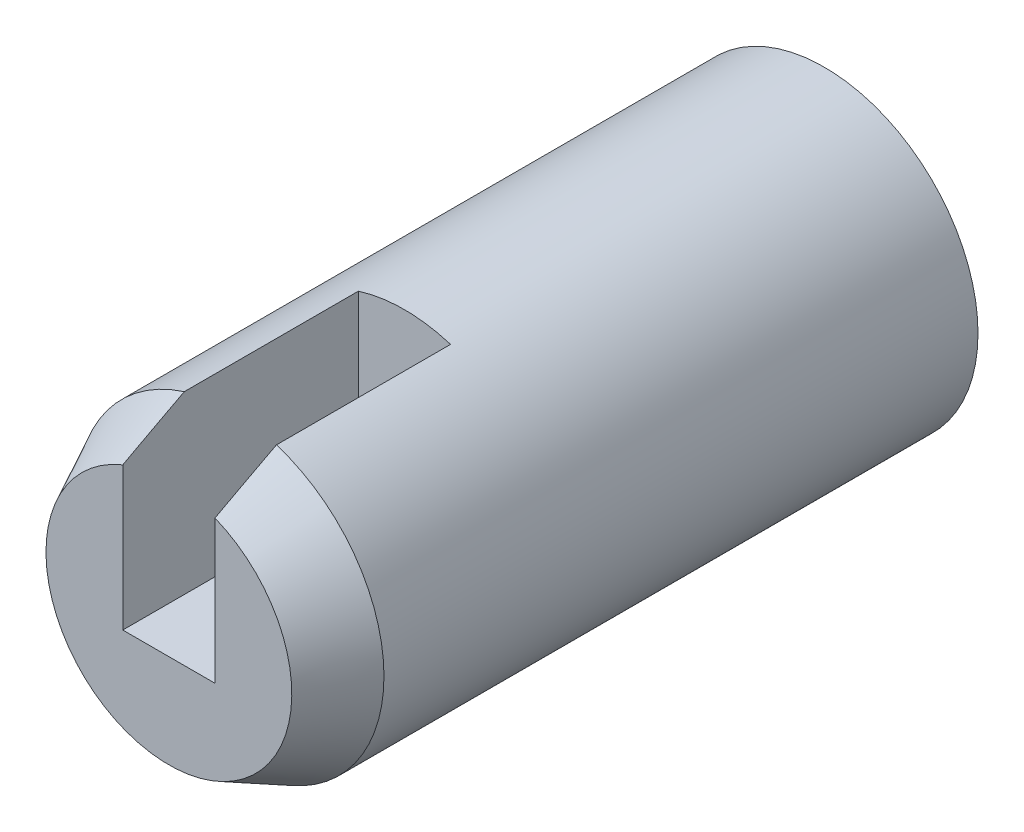
from build123d import *

# Parameters (mm, degrees)
ESQUISSE1_R             = 7.5
BOSS_EXTRU_2_DEPTH      = 29
ESQUISSE10_R            = 6
ESQUISSE11_R            = 6
ENL_V_MAT_EXTRU_1_DEPTH = 8
ENL_V_MAT_EXTRU_2_DEPTH = 11.5


with BuildPart() as part:
    # Esquisse1 → Boss.-Extru.2 (new body)
    with BuildSketch(Plane.XY):
        with Locations(Location((-15.770569557, 6.529797245, 0), (0, 0, 180))):
            Circle(ESQUISSE1_R)
    extrude(amount=BOSS_EXTRU_2_DEPTH)

    # Esquisse10 → section 1 of lissage3
    with BuildSketch(Plane.XY.offset(32), mode=Mode.PRIVATE) as lissage3_s1:
        with Locations((-15.770569557, 6.529797245)):
            Circle(ESQUISSE10_R)
    # loft up to a face of the part (lissage3)
    loft([Face(Wire([part.edges().sort_by_distance((-10.636466262, 1.062532539, 29))[0]])), lissage3_s1.sketch])

    # Esquisse11 → Enlèv. mat.-Extru.1 (cut)
    with BuildSketch(Plane(origin=(0, 0, 0), x_dir=(-1, 0, 0), z_dir=(0, 0, -1))):
        with Locations((15.770569557, 6.529797245)):
            Circle(ESQUISSE11_R)
    extrude(amount=-ENL_V_MAT_EXTRU_1_DEPTH, mode=Mode.SUBTRACT)

    # Esquisse13 → Enlèv. mat.-Extru.2 (cut)
    with BuildSketch(Plane.XY.offset(32)):
        Polygon((-15.770569557, 5.107185968), (-18.020569557, 5.107185968), (-18.020569557, 15.896170682), (-13.520569557, 15.896170682), (-13.520569557, 5.107185968), align=None)
    extrude(amount=-ENL_V_MAT_EXTRU_2_DEPTH, mode=Mode.SUBTRACT)


solid = part.part
